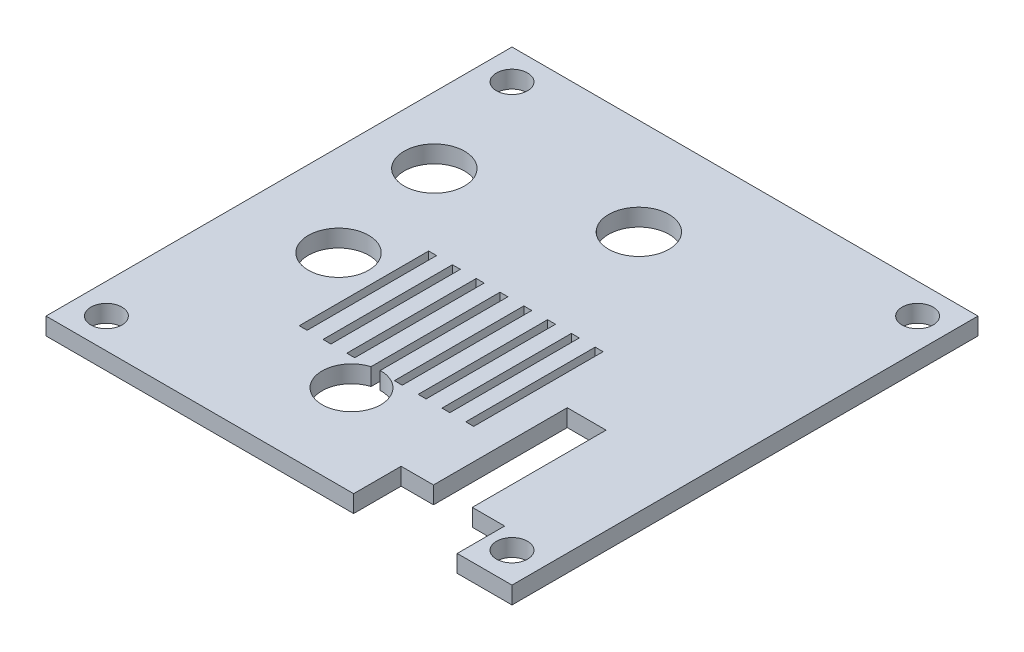
from build123d import *

# Parameters (mm, degrees)
SKETCH_3_R      = 3.5
SKETCH_3_W      = 0.91875
SKETCH_3_H      = 15
SKETCH_3_R_2    = 1.8
EXTRUDE_2_DEPTH = 2


with BuildPart() as part:
    # 草图3 → 凸台-拉伸2 (new body)
    with BuildSketch(Plane(origin=(0, 0, 0), x_dir=(1, 0, 0), z_dir=(0, 1, 0))):
        Polygon((16.9, -21.5), (20.65, -21.5), (20.65, -27), (27, -27), (27, 27), (-27, 27), (-27, -27), (8.65, -27), (8.65, -21.5), (12.4, -21.5), (12.4, -6), (16.9, -6), align=None)
        with Locations((-19.3, 10.3)):
            Circle(SKETCH_3_R, mode=Mode.SUBTRACT)
        with Locations((-16.4, -3.7)):
            Circle(SKETCH_3_R, mode=Mode.SUBTRACT)
        with Locations((-10.896875, -5.8)):
            Rectangle(SKETCH_3_W, SKETCH_3_H, mode=Mode.SUBTRACT)
        with BuildLine():
            Line((-3.0875, -13.246564316), (-3.0875, 1.7))
            Line((-3.0875, 1.7), (-2.16875, 1.7))
            Line((-2.16875, 1.7), (-2.16875, -13.100695154))
            ThreePointArc((-2.16875, -13.100695154), (-1.566862617, -19.857940519), (-3.0875, -13.246564316))
        make_face(mode=Mode.SUBTRACT)
        with Locations((-8.140625, -5.8)):
            Rectangle(SKETCH_3_W, SKETCH_3_H, mode=Mode.SUBTRACT)
        with Locations((-5.384375, -5.8)):
            Rectangle(SKETCH_3_W, SKETCH_3_H, mode=Mode.SUBTRACT)
        with Locations((0.128125, -5.8)):
            Rectangle(SKETCH_3_W, SKETCH_3_H, mode=Mode.SUBTRACT)
        with Locations((23.5, -23.5)):
            Circle(SKETCH_3_R_2, mode=Mode.SUBTRACT)
        with Locations((2.884375, -5.8)):
            Rectangle(SKETCH_3_W, SKETCH_3_H, mode=Mode.SUBTRACT)
        with Locations((5.640625, -5.8)):
            Rectangle(SKETCH_3_W, SKETCH_3_H, mode=Mode.SUBTRACT)
        with Locations((8.396875, -5.8)):
            Rectangle(SKETCH_3_W, SKETCH_3_H, mode=Mode.SUBTRACT)
        with Locations((-1.1, 15.8)):
            Circle(SKETCH_3_R, mode=Mode.SUBTRACT)
        with Locations((23.5, 23.5)):
            Circle(SKETCH_3_R_2, mode=Mode.SUBTRACT)
        with Locations((-23.5, -23.5)):
            Circle(SKETCH_3_R_2, mode=Mode.SUBTRACT)
        with Locations((-23.5, 23.5)):
            Circle(SKETCH_3_R_2, mode=Mode.SUBTRACT)
    extrude(amount=EXTRUDE_2_DEPTH)


solid = part.part
